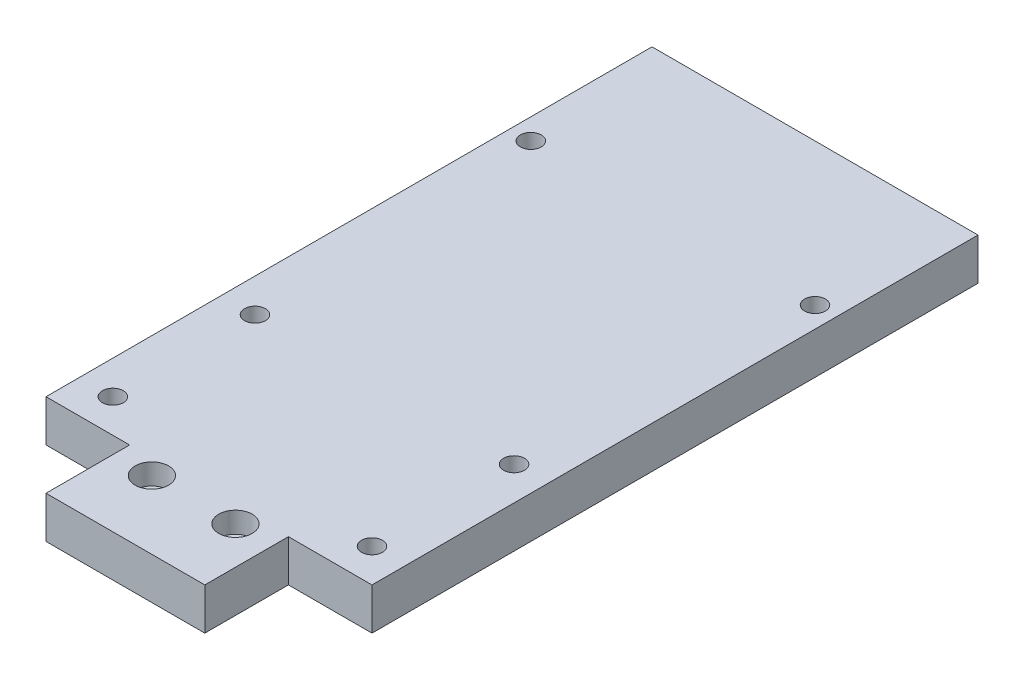
from build123d import *

# Parameters (mm, degrees)
BOSS_EXTRUDE1_DEPTH = 10
SKETCH2_R           = 4
CUT_EXTRUDE1_DEPTH  = 5
SKETCH3_R           = 2.5
CUT_EXTRUDE2_DEPTH  = 6
SKETCH5_R           = 4
CUT_EXTRUDE3_DEPTH  = 5
SKETCH6_R           = 2.5
CUT_EXTRUDE4_DEPTH  = 5


with BuildPart() as part:
    # Sketch1 → Boss-Extrude1 (new body)
    with BuildSketch(Plane(origin=(0, 0, 0), x_dir=(1, 0, 0), z_dir=(0, 1, 0))):
        Polygon((0, 0), (38, 0), (38, 20), (58, 20), (58, 165), (-20, 165), (-20, 20), (0, 20), align=None)
    extrude(amount=BOSS_EXTRUDE1_DEPTH)

    # Sketch2 → Cut-Extrude1 (cut)
    with BuildSketch(Plane(origin=(0, 10, 0), x_dir=(1, 0, 0), z_dir=(0, 1, 0))):
        with Locations((9, 16.329867595)):
            Circle(SKETCH2_R)
        with Locations((29, 16.329867595)):
            Circle(SKETCH2_R)
    extrude(amount=-CUT_EXTRUDE1_DEPTH, mode=Mode.SUBTRACT)

    # Sketch3 → Cut-Extrude2 (cut, through all)
    with BuildSketch(Plane(origin=(0, 5, 0), x_dir=(1, 0, 0), z_dir=(0, 1, 0))):
        with Locations((9, 16.329867595)):
            Circle(SKETCH3_R)
        with Locations((29, 16.329867595)):
            Circle(SKETCH3_R)
    extrude(amount=-CUT_EXTRUDE2_DEPTH, mode=Mode.SUBTRACT)

    # Sketch5 → Cut-Extrude3 (cut)
    with BuildSketch(Plane.XZ):
        with Locations((-15, -131)):
            Circle(SKETCH5_R)
        with Locations((53, -131)):
            Circle(SKETCH5_R)
        with Locations((-12, -28)):
            Circle(SKETCH5_R)
        with Locations((50, -28)):
            Circle(SKETCH5_R)
        with Locations((-12, -62)):
            Circle(SKETCH5_R)
        with Locations((50, -62)):
            Circle(SKETCH5_R)
    extrude(amount=-CUT_EXTRUDE3_DEPTH, mode=Mode.SUBTRACT)

    # Sketch6 → Cut-Extrude4 (cut)
    with BuildSketch(Plane.XZ.offset(-5)):
        with Locations((-15, -131)):
            Circle(SKETCH6_R)
        with Locations((53, -131)):
            Circle(SKETCH6_R)
        with Locations((-12, -28)):
            Circle(SKETCH6_R)
        with Locations((50, -28)):
            Circle(SKETCH6_R)
        with Locations((-12, -62)):
            Circle(SKETCH6_R)
        with Locations((50, -62)):
            Circle(SKETCH6_R)
    extrude(amount=-CUT_EXTRUDE4_DEPTH, mode=Mode.SUBTRACT)


solid = part.part
